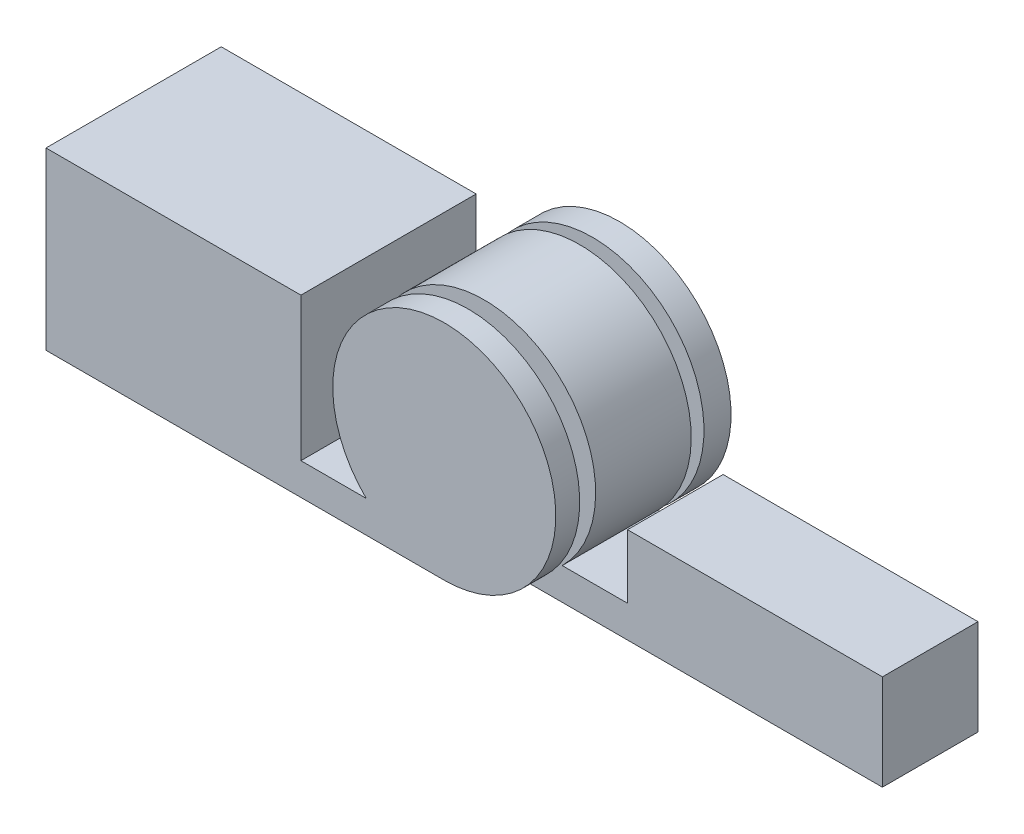
from build123d import *

# Parameters (mm, degrees)
BOSS_EXTRUDE1_DEPTH      = 139.7
SKETCH2_R                = 88.9
CUT_EXTRUDE1_DEPTH       = 50.8
CUT_EXTRUDE1_DEPTH_BACK  = 48.26
BOSS_EXTRUDE3_DEPTH      = 38.1
BOSS_EXTRUDE3_DEPTH_BACK = 38.1


with BuildPart() as part:
    # Sketch1 → Boss-Extrude1 (new body)
    with BuildSketch(Plane.XY):
        with BuildLine():
            Line((0, 0), (203.2, 0))
            Line((203.2, 0), (317.5, 0))
            ThreePointArc((317.5, 0), (351.101041651, 171.20540687), (255.282960533, 25.4))
            Line((255.282960533, 25.4), (203.2, 25.4))
            Line((203.2, 25.4), (203.2, 139.7))
            Line((203.2, 139.7), (0, 139.7))
            Line((0, 139.7), (0, 0))
        make_face()
    extrude(amount=BOSS_EXTRUDE1_DEPTH)

    # Sketch2 → Cut-Extrude1 (cut, two sides)
    with BuildSketch(Plane.XY.offset(69.85)) as cut_extrude1_sk:
        with Locations((317.5, 88.9)):
            Circle(SKETCH2_R)
    extrude(amount=CUT_EXTRUDE1_DEPTH, mode=Mode.SUBTRACT)
    extrude(cut_extrude1_sk.sketch, amount=-CUT_EXTRUDE1_DEPTH_BACK, mode=Mode.SUBTRACT)

    # Sketch5 → Boss-Extrude3 (add, two sides)
    with BuildSketch(Plane.XY.offset(69.85)) as boss_extrude3_sk:
        with BuildLine():
            Line((317.5, 0), (431.8, 0))
            Line((431.8, 0), (635, 0))
            Line((635, 0), (635, 76.2))
            Line((635, 76.2), (431.8, 76.2))
            Line((431.8, 76.2), (431.8, 25.4))
            Line((431.8, 25.4), (379.717039467, 25.4))
            ThreePointArc((379.717039467, 25.4), (283.898958349, 171.20540687), (317.5, 0))
        make_face()
    extrude(amount=BOSS_EXTRUDE3_DEPTH)
    extrude(boss_extrude3_sk.sketch, amount=-BOSS_EXTRUDE3_DEPTH_BACK)


solid = part.part
